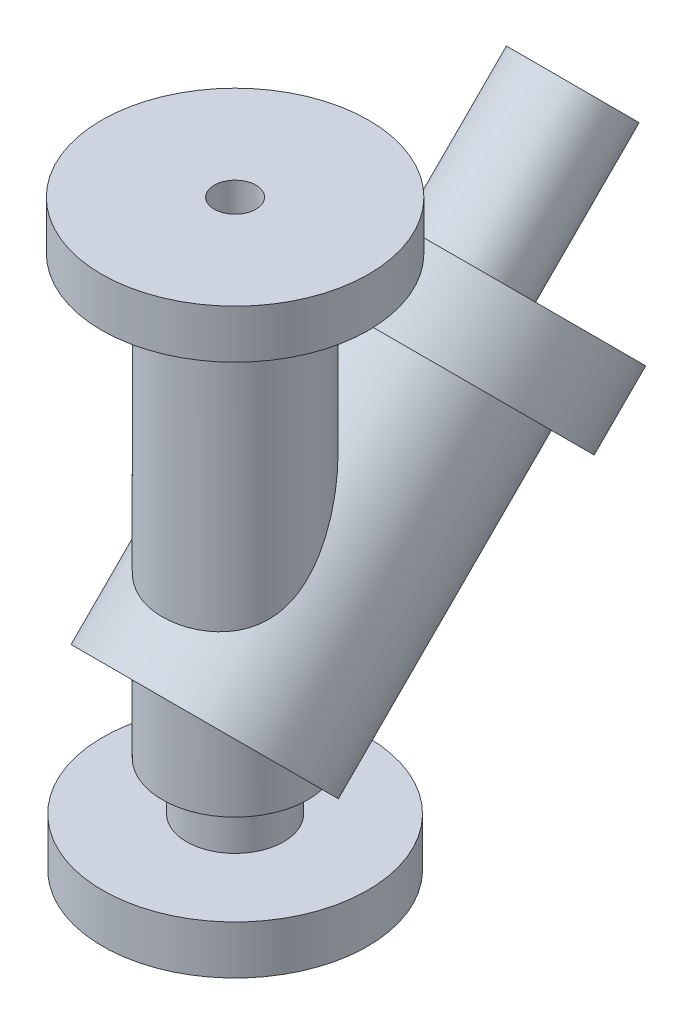
from build123d import *

# Parameters (mm, degrees)
SKETCH1_R      = 12.7
SKETCH1_R_2    = 5.461
EXTRUDE1_DEPTH = 25.4
SKETCH2_R      = 19.05
SKETCH2_R_2    = 5.461
EXTRUDE2_DEPTH = 127
SKETCH5_R      = 34.671
SKETCH5_R_2    = 12.7
EXTRUDE3_DEPTH = 12.7
SKETCH7_R      = 37.719
EXTRUDE4_DEPTH = 19.05
SKETCH9_R      = 28.575
EXTRUDE6_DEPTH = 97.79
SKETCH10_R     = 14.187120342
EXTRUDE7_DEPTH = 38.354
SKETCH11_R     = 34.925
EXTRUDE8_DEPTH = 12.7
SKETCH12_R     = 5.461
EXTRUDE9_DEPTH = 153.4


with BuildPart() as part:
    # Sketch1 → Extrude1 (new body)
    with BuildSketch(Plane(origin=(0, 0, 0), x_dir=(1, 0, 0), z_dir=(0, 1, 0))):
        Circle(SKETCH1_R)
        Circle(SKETCH1_R_2, mode=Mode.SUBTRACT)
    extrude(amount=EXTRUDE1_DEPTH)

    # Sketch2 → Extrude2 (add)
    with BuildSketch(Plane(origin=(0, 25.4, 0), x_dir=(1, 0, 0), z_dir=(0, 1, 0))):
        Circle(SKETCH2_R)
        Circle(SKETCH2_R_2, mode=Mode.SUBTRACT)
    extrude(amount=EXTRUDE2_DEPTH)

    # Sketch5 → Extrude3 (add)
    with BuildSketch(Plane.XZ):
        Circle(SKETCH5_R)
        Circle(SKETCH5_R_2, mode=Mode.SUBTRACT)
    extrude(amount=-EXTRUDE3_DEPTH)



with BuildPart() as body_2:
    # Sketch7 → Extrude4 (new body)
    with BuildSketch(Plane(origin=(0, 106.68136068, -61.21263932), x_dir=(-1, 0, 0), z_dir=(0, -0.707106781, 0.707106781))):
        Circle(SKETCH7_R)
    extrude(amount=EXTRUDE4_DEPTH)


with BuildPart() as part_1:
    add(part.part)

    add(body_2.part)  # Extrude6 merges body 2
    # Sketch9 → Extrude6 (add)
    with BuildSketch(Plane(origin=(0, 83.947, -83.947), x_dir=(1, 0, 0), z_dir=(0, 0.707106781, -0.707106781))):
        with Locations((0, -32.151241205)):
            Circle(SKETCH9_R)
    extrude(amount=-EXTRUDE6_DEPTH)

    # Sketch10 → Extrude7 (add)
    with BuildSketch(Plane(origin=(0, 83.947, -83.947), x_dir=(1, 0, 0), z_dir=(0, 0.707106781, -0.707106781))):
        with Locations((0, -32.151241205)):
            Circle(SKETCH10_R)
    extrude(amount=EXTRUDE7_DEPTH)

    # Sketch11 → Extrude8 (add)
    with BuildSketch(Plane(origin=(0, 152.4, 0), x_dir=(1, 0, 0), z_dir=(0, 1, 0))):
        Circle(SKETCH11_R)
    extrude(amount=-EXTRUDE8_DEPTH)

    # Sketch12 → Extrude9 (cut, through all)
    with BuildSketch(Plane.XZ):
        Circle(SKETCH12_R)
    extrude(amount=-EXTRUDE9_DEPTH, mode=Mode.SUBTRACT)


solid = part_1.part
